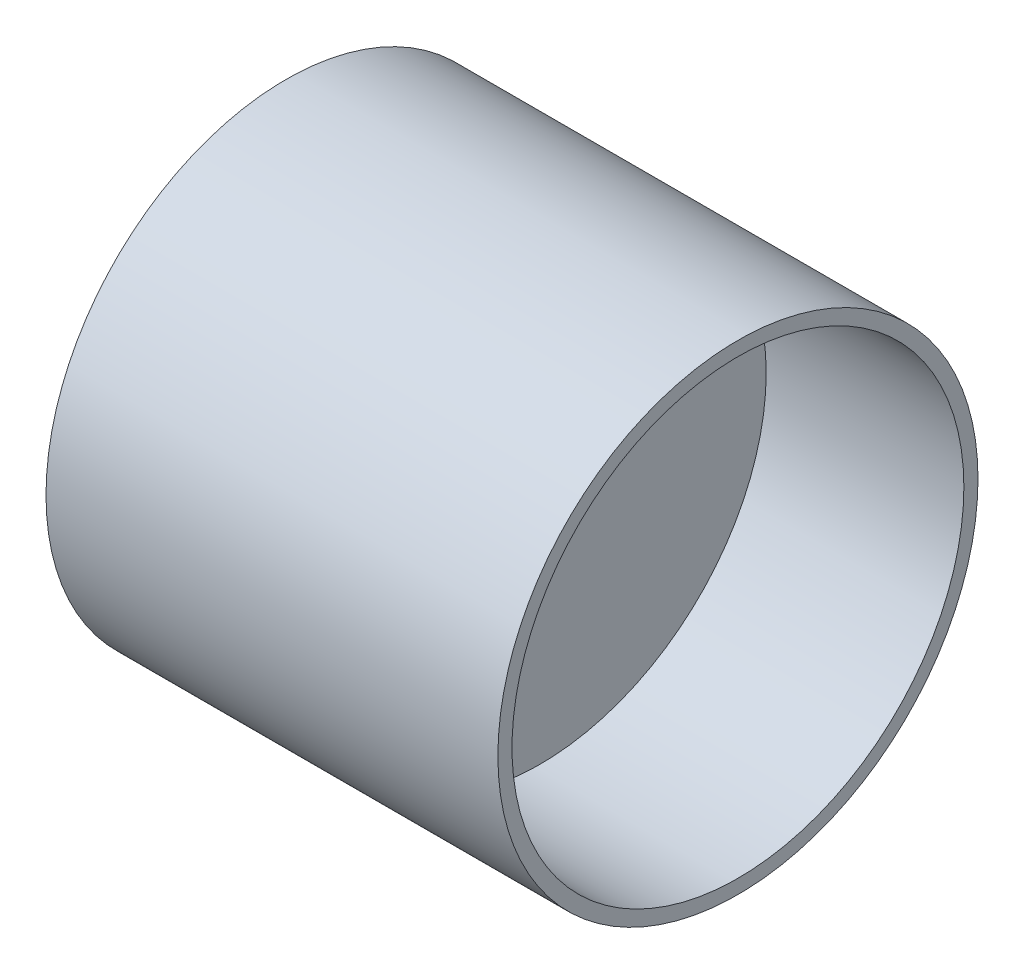
from build123d import *

# Parameters (mm, degrees)
SKETCH1_R           = 42.5
BOSS_EXTRUDE1_DEPTH = 50
SKETCH6_R           = 40
CUT_EXTRUDE6_DEPTH  = 35
SKETCH9_R           = 42.5
CUT_EXTRUDE12_DEPTH = 20


with BuildPart() as part:
    # Sketch1 → Boss-Extrude1 (new body, symmetric)
    with BuildSketch(Plane(origin=(0, 0, 0), x_dir=(0, 0, -1), z_dir=(1, 0, 0))):
        Circle(SKETCH1_R)
    extrude(amount=BOSS_EXTRUDE1_DEPTH, both=True)

    # Sketch6 → Cut-Extrude6 (cut)
    with BuildSketch(Plane(origin=(50, 0, 0), x_dir=(0, 0, -1), z_dir=(1, 0, 0))):
        Circle(SKETCH6_R)
    extrude(amount=-CUT_EXTRUDE6_DEPTH, mode=Mode.SUBTRACT)

    # Sketch9 → Cut-Extrude12 (cut)
    with BuildSketch(Plane.ZY.offset(50)):
        Circle(SKETCH9_R)
    extrude(amount=-CUT_EXTRUDE12_DEPTH, mode=Mode.SUBTRACT)


solid = part.part
